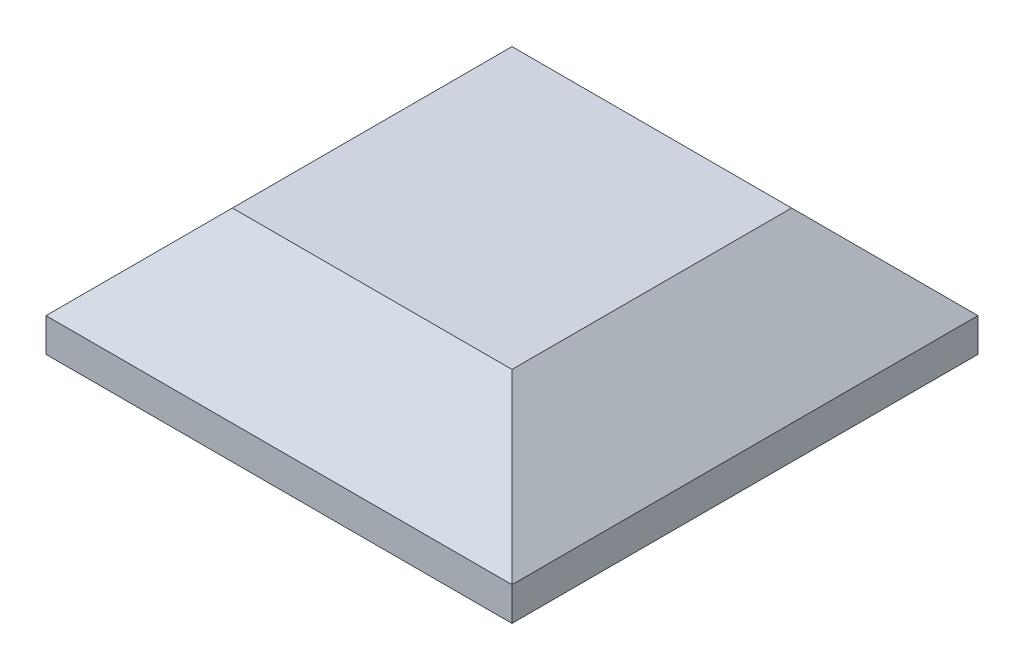
from build123d import *

# Parameters (mm, degrees)
SKETCH1_W           = 12.5
SKETCH1_H           = 12.5
BOSS_EXTRUDE1_DEPTH = 3.4
CHAMFER2_SIZE       = 2.5


with BuildPart() as part:
    # Sketch1 → Boss-Extrude1 (new body)
    with BuildSketch(Plane(origin=(0, 0, 0), x_dir=(1, 0, 0), z_dir=(0, 1, 0))):
        with Locations((-5.534957627, 1.218220339)):
            Rectangle(SKETCH1_W, SKETCH1_H)
    extrude(amount=BOSS_EXTRUDE1_DEPTH)

    # Chamfer2
    chamfer2_edges = [part.edges().sort_by_distance(p)[0] for p in [
        (-11.784957627, 3.4, -1.218220339),
        (-5.534957627, 3.4, 5.031779661),
        (0.715042373, 3.4, -1.218220339),
        (-5.534957627, 3.4, -7.468220339),
    ]]
    chamfer(chamfer2_edges, length=CHAMFER2_SIZE)


solid = part.part
